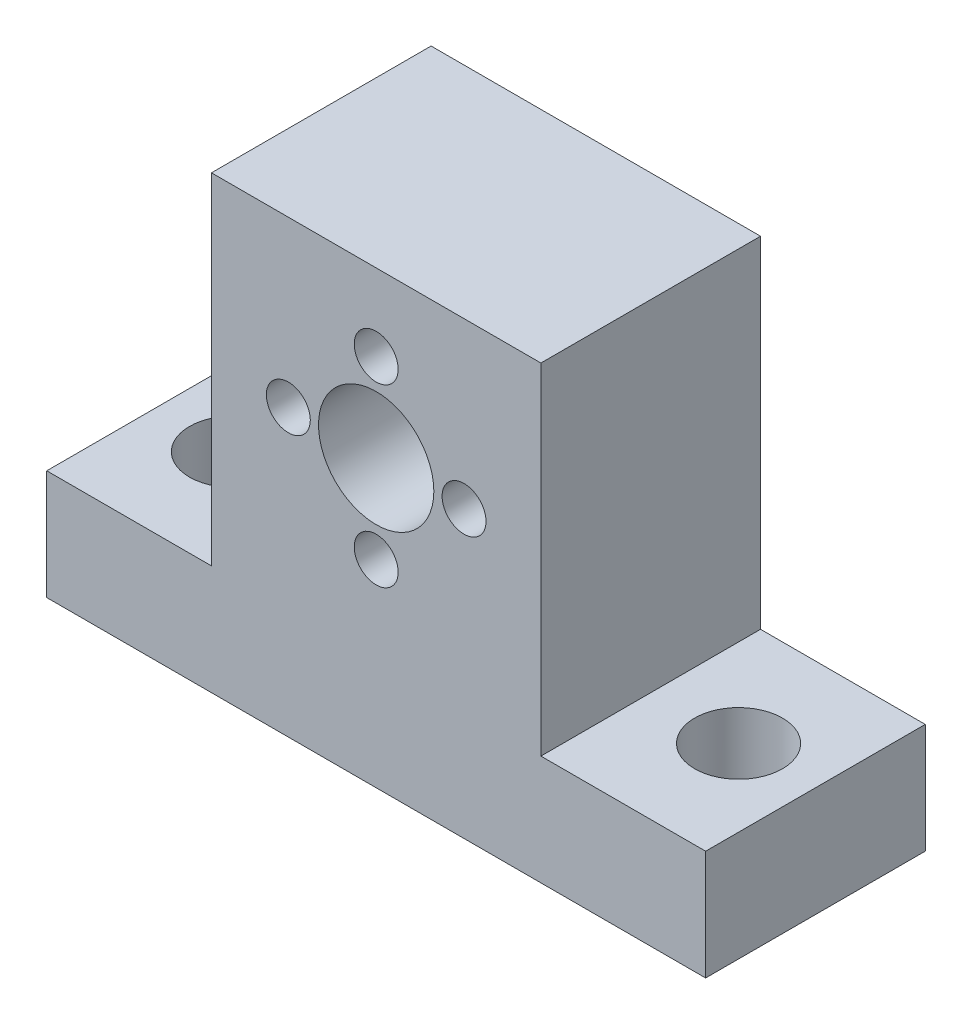
from build123d import *

# Parameters (mm, degrees)
SKETCH1_W           = 60
SKETCH1_H           = 41
SKETCH1_R           = 5.25
SKETCH1_R_2         = 2
BOSS_EXTRUDE1_DEPTH = 20
SKETCH2_R           = 4
CUT_EXTRUDE1_DEPTH  = 42
SKETCH3_W           = 15
SKETCH3_H           = 31
CUT_EXTRUDE2_DEPTH  = 21


with BuildPart() as part:
    # Sketch1 → Boss-Extrude1 (new body)
    with BuildSketch(Plane.XY):
        with Locations((0, -5.5)):
            Rectangle(SKETCH1_W, SKETCH1_H)
        Circle(SKETCH1_R, mode=Mode.SUBTRACT)
        with Locations((0, 8)):
            Circle(SKETCH1_R_2, mode=Mode.SUBTRACT)
        with Locations((8, 0)):
            Circle(SKETCH1_R_2, mode=Mode.SUBTRACT)
        with Locations((0, -8)):
            Circle(SKETCH1_R_2, mode=Mode.SUBTRACT)
        with Locations((-8, 0)):
            Circle(SKETCH1_R_2, mode=Mode.SUBTRACT)
    extrude(amount=BOSS_EXTRUDE1_DEPTH)

    # Sketch2 → Cut-Extrude1 (cut, through all)
    with BuildSketch(Plane(origin=(0, 15, 0), x_dir=(1, 0, 0), z_dir=(0, 1, 0))):
        with Locations((-23, -10)):
            Circle(SKETCH2_R)
        with Locations((23, -10)):
            Circle(SKETCH2_R)
    extrude(amount=-CUT_EXTRUDE1_DEPTH, mode=Mode.SUBTRACT)

    # Sketch3 → Cut-Extrude2 (cut, through all)
    with BuildSketch(Plane(origin=(0, 0, 0), x_dir=(-1, 0, 0), z_dir=(0, 0, -1))):
        with Locations((22.5, -0.5)):
            Rectangle(SKETCH3_W, SKETCH3_H)
        with Locations((-22.5, -0.5)):
            Rectangle(SKETCH3_W, SKETCH3_H)
    extrude(amount=-CUT_EXTRUDE2_DEPTH, mode=Mode.SUBTRACT)


solid = part.part
